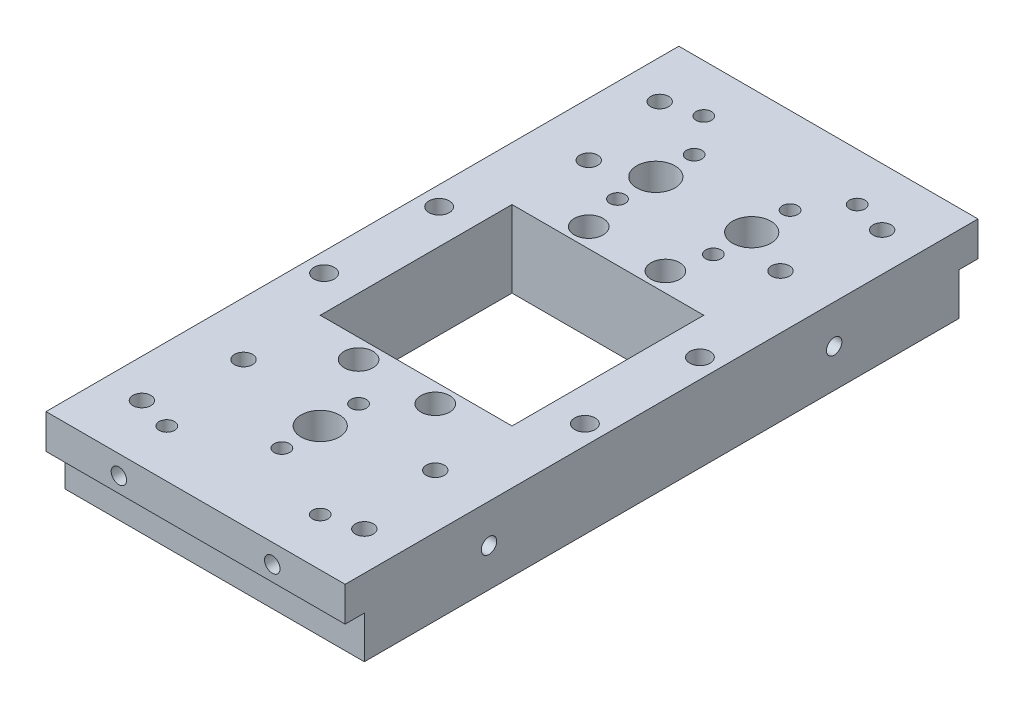
from build123d import *

# Parameters (mm, degrees)
SKETCH1_W                                        = 99.06
SKETCH1_H                                        = 209.55
BOSS_EXTRUDE1_DEPTH                              = 12.7
SKETCH2_W                                        = 63.5
SKETCH2_H                                        = 63.5
CUT_EXTRUDE1_DEPTH                               = 25.4
F_1_4_20_TAPPED_HOLE1_AT_2_COUNT                 = 2
F_1_4_20_TAPPED_HOLE1_AT_2_PITCH                 = 50.8
CBORE_FOR_1_4_SOCKET_HEAD_CAP_SCREW1_D           = 6.7564
CBORE_FOR_1_4_SOCKET_HEAD_CAP_SCREW1_CBORE_D     = 11.1125
CBORE_FOR_1_4_SOCKET_HEAD_CAP_SCREW1_CBORE_DEPTH = 6.35
F_15_64_0_23438_DIAMETER_HOLE1_D                 = 5.953252
F_1_2_0_5_DIAMETER_HOLE1_D                       = 12.7
F_1_2_0_5_DIAMETER_HOLE1_DEPTH                   = 25.4
F_1_4_20_TAPPED_HOLE4_AT_2_COUNT                 = 2
F_1_4_20_TAPPED_HOLE4_AT_2_PITCH                 = 114.3
SKETCH15_R                                       = 4.7625
CUT_EXTRUDE2_DEPTH                               = 25.4
F_1_4_20_TAPPED_HOLE5_D                          = 5.1054
F_1_4_20_TAPPED_HOLE5_DEPTH                      = 25.4
F_1_4_20_TAPPED_HOLE6_D                          = 5.1054
SKETCH20_W                                       = 6.35
SKETCH20_H                                       = 13.97
CUT_EXTRUDE3_DEPTH                               = 99.06


with BuildPart() as part:
    # Sketch1 → Boss-Extrude1 (new body, symmetric)
    with BuildSketch(Plane(origin=(0, 0, 0), x_dir=(1, 0, 0), z_dir=(0, 1, 0))):
        Rectangle(SKETCH1_W, SKETCH1_H)
    extrude(amount=BOSS_EXTRUDE1_DEPTH, both=True)

    # Sketch2 → Cut-Extrude1 (cut)
    with BuildSketch(Plane(origin=(0, 12.7, 0), x_dir=(1, 0, 0), z_dir=(0, 1, 0))):
        Rectangle(SKETCH2_W, SKETCH2_H)
    extrude(amount=-CUT_EXTRUDE1_DEPTH, mode=Mode.SUBTRACT)

    # Sketch4 → 1/4-20 Tapped Hole1 (revolve, cut)
    with BuildSketch(Plane(origin=(-25.4, 6.35, 104.775), x_dir=(0, -1, 0), z_dir=(1, 0, 0))):
        Polygon((0, 0), (0, 20.583816902), (2.5527, 19.05), (2.5527, 0), align=None)
    f_1_4_20_tapped_hole1 = revolve(axis=Axis((-25.4, 6.35, 111.125), (0, 0, -1)), mode=Mode.SUBTRACT)

    # 1/4-20 Tapped Hole1 at 2: 1/4-20 Tapped Hole1 ×2
    with Locations(*[(i * F_1_4_20_TAPPED_HOLE1_AT_2_PITCH, 0, 0) for i in range(1, F_1_4_20_TAPPED_HOLE1_AT_2_COUNT)]):
        add(f_1_4_20_tapped_hole1, mode=Mode.SUBTRACT)

    # CBORE for 1/4 Socket Head Cap Screw1 (through all)
    with Locations(Plane(origin=(0, -12.7, 0), x_dir=(-1, 0, 0), z_dir=(0, -1, 0))):
        with Locations((43.18, 19.05), (43.18, -19.05), (-43.18, -19.05), (-43.18, 19.05)):
            CounterBoreHole(CBORE_FOR_1_4_SOCKET_HEAD_CAP_SCREW1_D / 2, CBORE_FOR_1_4_SOCKET_HEAD_CAP_SCREW1_CBORE_D / 2, CBORE_FOR_1_4_SOCKET_HEAD_CAP_SCREW1_CBORE_DEPTH)

    # 15/64 (0.23438) Diameter Hole1 (through all)
    with Locations(Plane(origin=(0, 12.7, 0), x_dir=(1, 0, 0), z_dir=(0, 1, 0))):
        with Locations((-36.83, 85.725), (36.83, 85.725), (36.83, -85.725), (-36.83, -85.725), (-31.75, -57.15), (31.75, -57.15), (31.75, 57.15), (-31.75, 57.15)):
            Hole(F_15_64_0_23438_DIAMETER_HOLE1_D / 2)

    # 1/2 (0.5) Diameter Hole1
    with Locations(Plane(origin=(0, 12.7, 0), x_dir=(1, 0, 0), z_dir=(0, 1, 0))):
        with Locations((0, -63.5), (-15.875, 63.5), (15.875, 63.5)):
            Hole(F_1_2_0_5_DIAMETER_HOLE1_D / 2, depth=F_1_2_0_5_DIAMETER_HOLE1_DEPTH)

    # Mirror1: 1/4-20 Tapped Hole1 across plane
    add(f_1_4_20_tapped_hole1.mirror(Plane.XY), mode=Mode.SUBTRACT)

    # Mirror1 copy 1 sketch → Mirror1 copy 1 (revolve, cut)
    with BuildSketch(Plane(origin=(25.4, 6.35, -104.775), x_dir=(0, -1, 0), z_dir=(1, 0, 0))):
        Polygon((0, 0), (0, -20.583816902), (2.5527, -19.05), (2.5527, 0), align=None)
    revolve(axis=Axis((25.4, 6.35, -111.125), (0, 0, -1)), mode=Mode.SUBTRACT)

    # Sketch12 → 1/4-20 Tapped Hole4 (revolve, cut)
    with BuildSketch(Plane(origin=(49.53, 0, 57.15), x_dir=(0, 0, -1), z_dir=(0, 1, 0))):
        Polygon((0, 0), (0, 21.853816902), (2.5527, 20.32), (2.5527, 0), align=None)
    f_1_4_20_tapped_hole4 = revolve(axis=Axis((55.88, 0, 57.15), (-1, 0, 0)), mode=Mode.SUBTRACT)

    # 1/4-20 Tapped Hole4 at 2: 1/4-20 Tapped Hole4 ×2
    with Locations(*[(0, 0, -i * F_1_4_20_TAPPED_HOLE4_AT_2_PITCH) for i in range(1, F_1_4_20_TAPPED_HOLE4_AT_2_COUNT)]):
        add(f_1_4_20_tapped_hole4, mode=Mode.SUBTRACT)

    # Mirror2: 1/4-20 Tapped Hole4 across plane
    add(f_1_4_20_tapped_hole4.mirror(Plane(origin=(0, 0, 0), x_dir=(0, 0, 1), z_dir=(1, 0, 0))), mode=Mode.SUBTRACT)

    # Mirror2 copy 1 sketch → Mirror2 copy 1 (revolve, cut)
    with BuildSketch(Plane(origin=(-49.53, 0, -57.15), x_dir=(0, 0, -1), z_dir=(0, 1, 0))):
        Polygon((0, 0), (0, -21.853816902), (2.5527, -20.32), (2.5527, 0), align=None)
    revolve(axis=Axis((-55.88, 0, -57.15), (-1, 0, 0)), mode=Mode.SUBTRACT)

    # Sketch15 → Cut-Extrude2 (cut)
    with BuildSketch(Plane(origin=(0, 12.7, 0), x_dir=(1, 0, 0), z_dir=(0, 1, 0))):
        with Locations((12.7, -38.1)):
            Circle(SKETCH15_R)
        with Locations((-12.7, -38.1)):
            Circle(SKETCH15_R)
    cut_extrude2 = extrude(amount=-CUT_EXTRUDE2_DEPTH, mode=Mode.SUBTRACT)

    # Mirror3: Cut-Extrude2 across plane
    add(cut_extrude2.mirror(Plane.XY), mode=Mode.SUBTRACT)

    # 1/4-20 Tapped Hole5
    with Locations(Plane(origin=(0, 12.7, 0), x_dir=(1, 0, 0), z_dir=(0, 1, 0))):
        with Locations((0, -76.2), (0, -50.8), (15.875, 50.8), (15.875, 76.2), (-15.875, 50.8), (-15.875, 76.2)):
            Hole(F_1_4_20_TAPPED_HOLE5_D / 2, depth=F_1_4_20_TAPPED_HOLE5_DEPTH)

    # 1/4-20 Tapped Hole6 (through all)
    with Locations(Plane(origin=(0, 12.7, 0), x_dir=(1, 0, 0), z_dir=(0, 1, 0))):
        with Locations((-25.4, -88.9), (25.4, -88.9)):
            f_1_4_20_tapped_hole6 = Hole(F_1_4_20_TAPPED_HOLE6_D / 2)

    # Mirror4: 1/4-20 Tapped Hole6 across plane
    add(f_1_4_20_tapped_hole6.mirror(Plane.XY), mode=Mode.SUBTRACT)

    # Sketch20 → Cut-Extrude3 (cut)
    with BuildSketch(Plane(origin=(49.53, 0, 0), x_dir=(0, 0, -1), z_dir=(1, 0, 0))):
        with Locations((-101.6, -5.715)):
            Rectangle(SKETCH20_W, SKETCH20_H)
    cut_extrude3 = extrude(amount=-CUT_EXTRUDE3_DEPTH, mode=Mode.SUBTRACT)

    # Mirror5: Cut-Extrude3 across plane
    add(cut_extrude3.mirror(Plane.XY), mode=Mode.SUBTRACT)


solid = part.part
